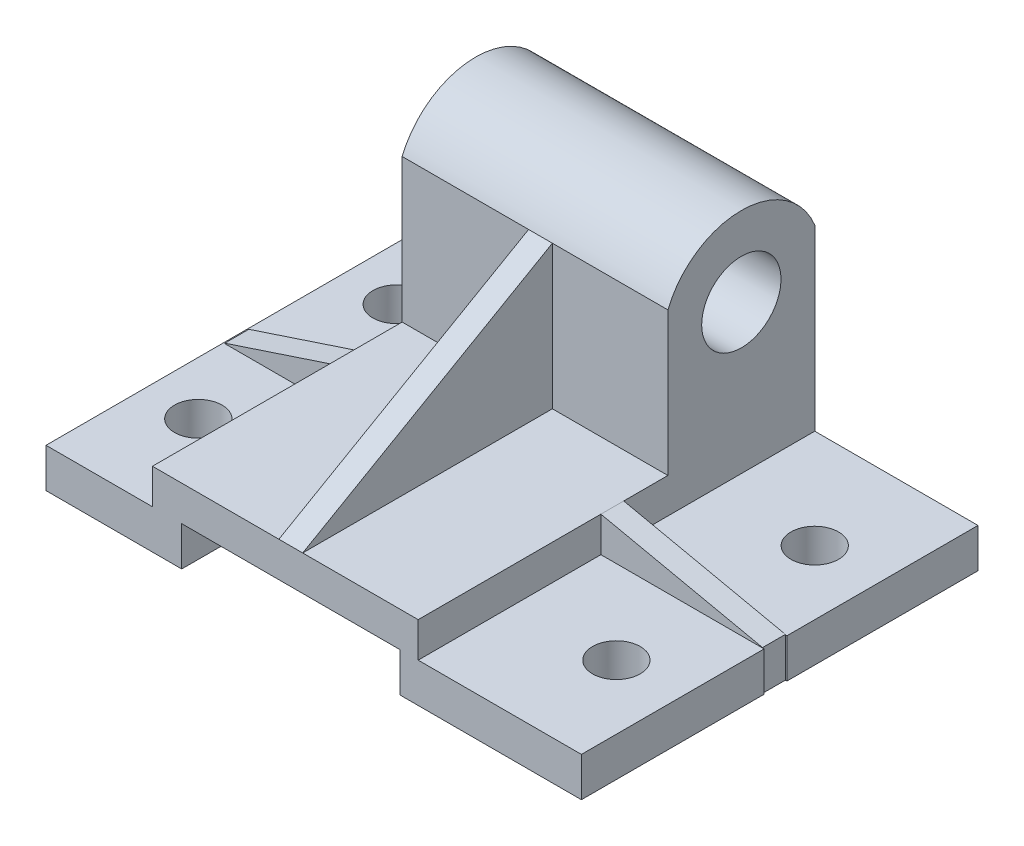
from build123d import *

# Parameters (mm, degrees)
BOSS_EXTRUDE1_DEPTH     = 100
SKETCH2_R               = 10
BOSS_EXTRUDE2_DEPTH     = 67
SKETCH3_R               = 6
CUT_EXTRUDE1_DEPTH      = 67
CUT_EXTRUDE2_DEPTH      = 67
CUT_EXTRUDE2_DEPTH_BACK = 67
SKETCH4_R               = 6
BOSS_EXTRUDE3_DEPTH     = 3
SKETCH9_W               = 6.067764808
SKETCH9_H               = 8.847787213
BOSS_EXTRUDE4_DEPTH     = 26.5
CUT_EXTRUDE3_DEPTH      = 26.5
SKETCH11_W              = 5.758839732
SKETCH11_H              = 8.847787213
BOSS_EXTRUDE5_DEPTH     = 42
CUT_EXTRUDE4_DEPTH      = 42
SKETCH13_W              = 1.235315599
SKETCH13_H              = 5.758839732
CUT_EXTRUDE6_DEPTH      = 42


with BuildPart() as part:
    # Sketch1 → Boss-Extrude1 (new body)
    with BuildSketch(Plane.XY):
        Polygon((-61.723716381, 0), (-27.5, 0), (-27.5, 9.902200489), (27.5, 9.902200489), (27.5, 0), (73.276283619, 0), (73.276283619, 9.902200489), (31.668314846, 9.902200489), (31.668314846, 18.749987702), (-34.880531234, 18.749987702), (-34.880531234, 9.902200489), (-61.723716381, 9.902200489), align=None)
    extrude(amount=-BOSS_EXTRUDE1_DEPTH)

    # Sketch2 → Boss-Extrude2 (add)
    with BuildSketch(Plane.ZY.offset(34.880531234)):
        with BuildLine():
            Line((-100, 9.902200489), (-100, 54.908843962))
            ThreePointArc((-100, 54.908843962), (-81.480595065, 67.356914351), (-62.96119013, 54.908843962))
            Line((-62.96119013, 54.908843962), (-62.96119013, 18.749987702))
            Line((-62.96119013, 18.749987702), (0, 18.749987702))
            Line((0, 18.749987702), (0, 9.902200489))
            Line((0, 9.902200489), (-100, 9.902200489))
        make_face()
        with Locations((-81.480595065, 47.356914351)):
            Circle(SKETCH2_R, mode=Mode.SUBTRACT)
    extrude(amount=-BOSS_EXTRUDE2_DEPTH)

    # Sketch3 → Cut-Extrude1 (cut)
    with BuildSketch(Plane(origin=(0, 9.902200489, 0), x_dir=(1, 0, 0), z_dir=(0, 1, 0))):
        with Locations((-48.302123808, 24.983488629)):
            Circle(SKETCH3_R)
        with Locations((-48.302123808, 75.004643802)):
            Circle(SKETCH3_R)
    extrude(amount=-CUT_EXTRUDE1_DEPTH, mode=Mode.SUBTRACT)

    # Sketch4 → Cut-Extrude2 (cut, two sides: drawn at the far end of the back side and taken through both)
    with BuildSketch(Plane(origin=(0, 0, 0), x_dir=(1, 0, 0), z_dir=(0, 1, 0)).offset(-CUT_EXTRUDE2_DEPTH_BACK)):
        with Locations((57.109031968, 75.004643802)):
            Circle(SKETCH4_R)
        with Locations((57.109031968, 24.983488629)):
            Circle(SKETCH4_R)
    extrude(amount=CUT_EXTRUDE2_DEPTH + CUT_EXTRUDE2_DEPTH_BACK, mode=Mode.SUBTRACT)

    # Sketch5 → Boss-Extrude3 (add, symmetric)
    with BuildSketch(Plane(origin=(0, 0, 0), x_dir=(0, 0, -1), z_dir=(1, 0, 0))):
        Polygon((62.96119013, 54.908843962), (0, 18.749987702), (62.96119013, 18.749987702), align=None)
    extrude(amount=BOSS_EXTRUDE3_DEPTH, both=True)

    # Sketch9 → Boss-Extrude4 (add)
    with BuildSketch(Plane.ZY.offset(34.880531234)):
        with Locations((-47.773735316, 14.326094096)):
            Rectangle(SKETCH9_W, SKETCH9_H)
    extrude(amount=BOSS_EXTRUDE4_DEPTH)

    # Sketch10 → Cut-Extrude3 (cut)
    with BuildSketch(Plane.XY.offset(-44.739852912)):
        Polygon((-34.880531234, 18.749987702), (-61.380531234, 10), (-61.380531234, 18.749987702), align=None)
    extrude(amount=-CUT_EXTRUDE3_DEPTH, mode=Mode.SUBTRACT)

    # Sketch11 → Boss-Extrude5 (add)
    with BuildSketch(Plane(origin=(32.119468766, 0, 0), x_dir=(0, 0, -1), z_dir=(1, 0, 0))):
        with Locations((48.947532941, 14.326094096)):
            Rectangle(SKETCH11_W, SKETCH11_H)
    extrude(amount=BOSS_EXTRUDE5_DEPTH)

    # Sketch12 → Cut-Extrude4 (cut)
    with BuildSketch(Plane(origin=(0, 0, -51.826952807), x_dir=(-1, 0, 0), z_dir=(0, 0, -1))):
        Polygon((-32.119468766, 18.749987702), (-72.884153167, 10), (-74.975846316, 10), (-74.119468766, 18.749987702), align=None)
    extrude(amount=-CUT_EXTRUDE4_DEPTH, mode=Mode.SUBTRACT)

    # Sketch13 → Cut-Extrude6 (cut)
    with BuildSketch(Plane(origin=(0, 10, 0), x_dir=(1, 0, 0), z_dir=(0, 1, 0))):
        with Locations((73.501810967, 48.947532941)):
            Rectangle(SKETCH13_W, SKETCH13_H)
    extrude(amount=-CUT_EXTRUDE6_DEPTH, mode=Mode.SUBTRACT)


solid = part.part
